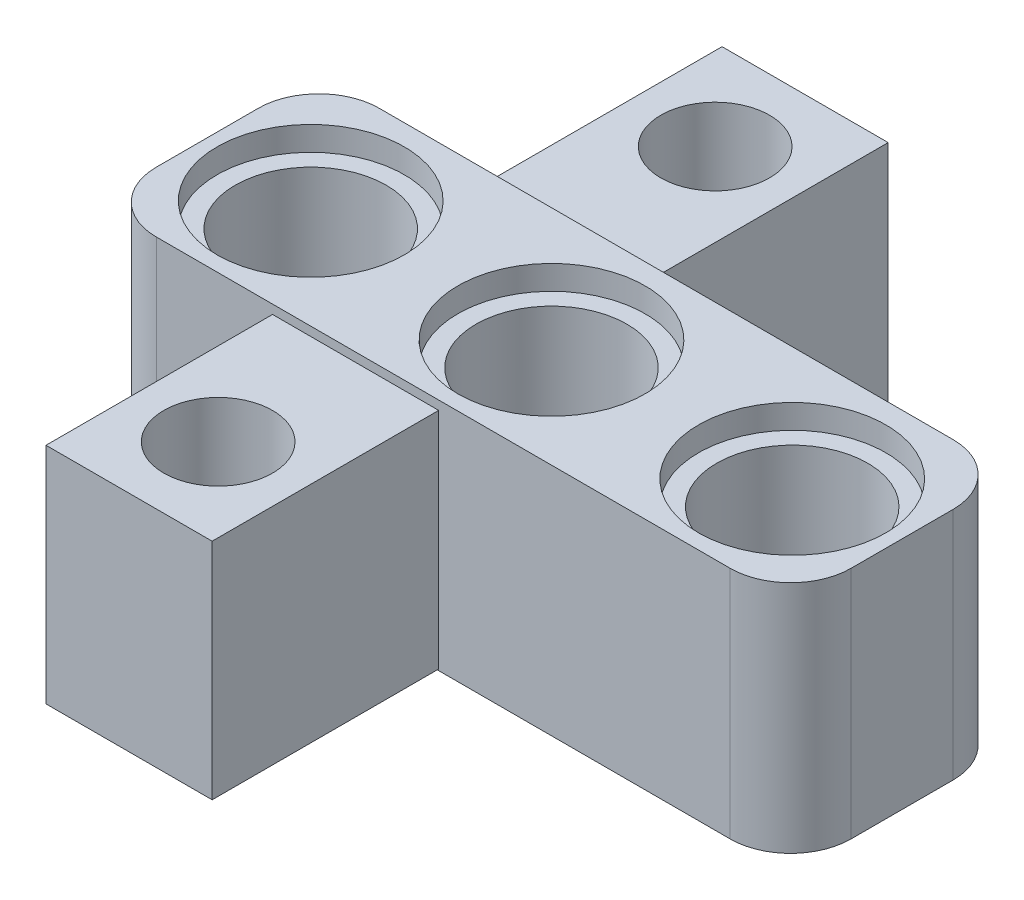
from build123d import *

# Parameters (mm, degrees)
SKETCH3_W           = 23
SKETCH3_H           = 7.38
BOSS_EXTRUDE1_DEPTH = 7.76
SKETCH4_R           = 3.1
CUT_EXTRUDE2_DEPTH  = 0.8
SKETCH7_R           = 3.1
CUT_EXTRUDE3_DEPTH  = 0.8
SKETCH6_R           = 2.5
CUT_EXTRUDE4_DEPTH  = 7.96
FILLET3_R           = 2
FILLET4_R           = 2
FILLET5_R           = 2
FILLET6_R           = 2
SKETCH8_W           = 5.5
SKETCH8_H           = 7.500541727
BOSS_EXTRUDE2_DEPTH = 7.5
SKETCH12_W          = 5.5
SKETCH12_H          = 7.41549866
BOSS_EXTRUDE4_DEPTH = 7.5
SKETCH9_R           = 1.8
CUT_EXTRUDE5_DEPTH  = 20.6
SKETCH13_R          = 1.8
CUT_EXTRUDE6_DEPTH  = 20.6
SKETCH14_R          = 2.3
CUT_EXTRUDE7_DEPTH  = 2.5


with BuildPart() as part:
    # Sketch3 → Boss-Extrude1 (new body)
    with BuildSketch(Plane(origin=(0, 0, 0), x_dir=(1, 0, 0), z_dir=(0, 1, 0))):
        with Locations((-11.5, 3.69)):
            Rectangle(SKETCH3_W, SKETCH3_H)
    extrude(amount=BOSS_EXTRUDE1_DEPTH)

    # Sketch4 → Cut-Extrude2 (cut)
    with BuildSketch(Plane(origin=(0, 0, 0), x_dir=(-1, 0, 0), z_dir=(0, -1, 0))):
        with Locations((19.538269405, 3.69)):
            Circle(SKETCH4_R)
        with Locations((11.538269405, 3.69)):
            Circle(SKETCH4_R)
        with Locations((3.538269405, 3.69)):
            Circle(SKETCH4_R)
    extrude(amount=-CUT_EXTRUDE2_DEPTH, mode=Mode.SUBTRACT)

    # Sketch7 → Cut-Extrude3 (cut)
    with BuildSketch(Plane(origin=(0, 7.76, 0), x_dir=(1, 0, 0), z_dir=(0, 1, 0))):
        with Locations((-19.478269405, 3.591470107)):
            Circle(SKETCH7_R)
        with Locations((-11.508269405, 3.591470107)):
            Circle(SKETCH7_R)
        with Locations((-3.538269405, 3.591470107)):
            Circle(SKETCH7_R)
    extrude(amount=-CUT_EXTRUDE3_DEPTH, mode=Mode.SUBTRACT)

    # Sketch6 → Cut-Extrude4 (cut, through all)
    with BuildSketch(Plane(origin=(0, 0.8, 0), x_dir=(-1, 0, 0), z_dir=(0, -1, 0))):
        with Locations((3.538269405, 3.591470107)):
            Circle(SKETCH6_R)
        with Locations((11.508269405, 3.591470107)):
            Circle(SKETCH6_R)
        with Locations((19.478269405, 3.591470107)):
            Circle(SKETCH6_R)
    extrude(amount=-CUT_EXTRUDE4_DEPTH, mode=Mode.SUBTRACT)

    # Fillet3
    fillet3_edges = [part.edges().sort_by_distance(p)[0] for p in [
        (0, 3.88, 0),
    ]]
    fillet(fillet3_edges, radius=FILLET3_R)

    # Fillet4
    fillet4_edges = [part.edges().sort_by_distance(p)[0] for p in [
        (-23, 3.88, 0),
    ]]
    fillet(fillet4_edges, radius=FILLET4_R)

    # Fillet5
    fillet5_edges = [part.edges().sort_by_distance(p)[0] for p in [
        (-23, 3.88, -7.38),
    ]]
    fillet(fillet5_edges, radius=FILLET5_R)

    # Fillet6
    fillet6_edges = [part.edges().sort_by_distance(p)[0] for p in [
        (0, 3.88, -7.38),
    ]]
    fillet(fillet6_edges, radius=FILLET6_R)

    # Sketch8 → Boss-Extrude2 (add)
    with BuildSketch(Plane(origin=(0, 0, -7.38), x_dir=(-1, 0, 0), z_dir=(0, 0, -1))):
        with Locations((14.4, 3.949980596)):
            Rectangle(SKETCH8_W, SKETCH8_H)
    extrude(amount=BOSS_EXTRUDE2_DEPTH)

    # Sketch12 → Boss-Extrude4 (add)
    with BuildSketch(Plane.XY):
        with Locations((-14.4, 3.755058696)):
            Rectangle(SKETCH12_W, SKETCH12_H)
    extrude(amount=BOSS_EXTRUDE4_DEPTH)

    # Sketch9 → Cut-Extrude5 (cut)
    with BuildSketch(Plane(origin=(0, 7.700251459, 0), x_dir=(1, 0, 0), z_dir=(0, 1, 0))):
        with Locations((-14.4, 11.902505055)):
            Circle(SKETCH9_R)
    extrude(amount=-CUT_EXTRUDE5_DEPTH, mode=Mode.SUBTRACT)

    # Sketch13 → Cut-Extrude6 (cut)
    with BuildSketch(Plane(origin=(0, 7.462808026, 0), x_dir=(1, 0, 0), z_dir=(0, 1, 0))):
        with Locations((-14.4, -4.550661236)):
            Circle(SKETCH13_R)
    extrude(amount=-CUT_EXTRUDE6_DEPTH, mode=Mode.SUBTRACT)

    # Sketch14 → Cut-Extrude7 (cut)
    with BuildSketch(Plane(origin=(0, 0, 0), x_dir=(-1, 0, 0), z_dir=(0, -1, 0))):
        with Locations((6.638269405, 3.69)):
            Circle(SKETCH14_R)
    extrude(amount=-CUT_EXTRUDE7_DEPTH, mode=Mode.SUBTRACT)


solid = part.part
